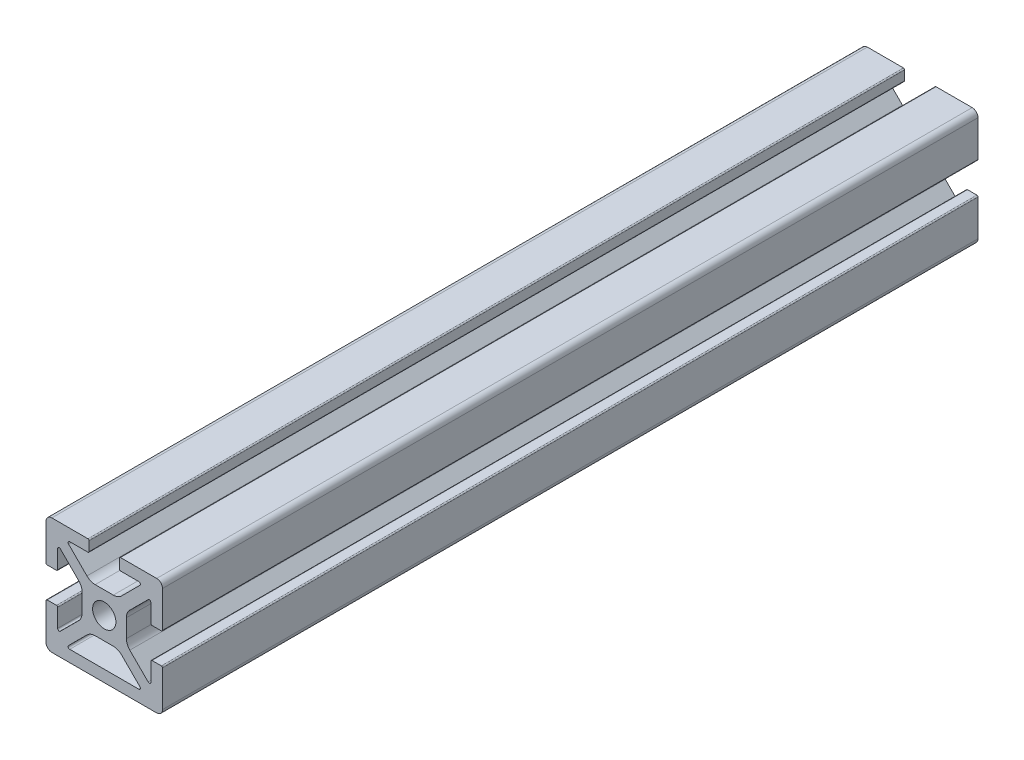
from build123d import *

# Parameters (mm, degrees)
BOSS_EXTRUDE1_DEPTH = 88.9
FILLET2_R           = 0.254
FILLET1_R           = 1.27
SKETCH5_W           = 7.112
SKETCH5_H           = 2.54
BOSS_EXTRUDE2_DEPTH = 177.8


with BuildPart() as part:
    # Sketch3 → Boss-Extrude1 (new body, symmetric)
    with BuildSketch(Plane.XY):
        with BuildLine():
            Line((-12.7, 12.7), (-1.796051224, 1.796051224))
            ThreePointArc((-1.796051224, 1.796051224), (-0.972015918, 2.346654013), (0, 2.54))
            Line((0, 2.54), (0, 4.826))
            Line((0, 4.826), (-1.977846327, 4.826))
            ThreePointArc((-1.977846327, 4.826), (-2.949862246, 5.019345987), (-3.773897552, 5.569948776))
            Line((-3.773897552, 5.569948776), (-7.772528286, 9.56857951))
            ThreePointArc((-7.772528286, 9.56857951), (-7.847628361, 9.946133082), (-7.527553898, 10.16))
            Line((-7.527553898, 10.16), (-3.302, 10.16))
            Line((-3.302, 10.16), (-3.302, 12.7))
            Line((-3.302, 12.7), (-12.7, 12.7))
        make_face()
    extrude(amount=BOSS_EXTRUDE1_DEPTH, both=True)

    # Fillet2
    fillet2_edges = [part.edges().sort_by_distance(p)[0] for p in [
        (-3.302, 12.7, 0),
        (-3.302, 10.16, 0),
    ]]
    fillet(fillet2_edges, radius=FILLET2_R)

    # Mirror1: part across plane


with BuildPart() as part_1:
    add(part.part)
    add(part.part.mirror(Plane(origin=(0, 0, 88.9), x_dir=(0, 0, 1), z_dir=(0.707106781, 0.707106781, 0))))

    # Fillet1
    fillet1_edges = [part_1.edges().sort_by_distance(p)[0] for p in [
        (-12.7, 12.7, 0),
    ]]
    fillet(fillet1_edges, radius=FILLET1_R)

    # Mirror2: part across plane


with BuildPart() as part_2:
    add(part_1.part)
    add(part_1.part.mirror(Plane(origin=(0, 0, 88.9), x_dir=(0, 0, 1), z_dir=(0, 1, 0))))

    # Mirror5: part across plane


with BuildPart() as part_3:
    add(part_2.part)
    add(part_2.part.mirror(Plane(origin=(0, 0, 88.9), x_dir=(0, 0, 1), z_dir=(-1, 0, 0))))

    # Sketch5 → Boss-Extrude2 (add, through all)
    with BuildSketch(Plane.XY.offset(88.9)):
        with Locations((0, -11.43)):
            Rectangle(SKETCH5_W, SKETCH5_H)
    extrude(amount=-BOSS_EXTRUDE2_DEPTH)


solid = part_3.part
